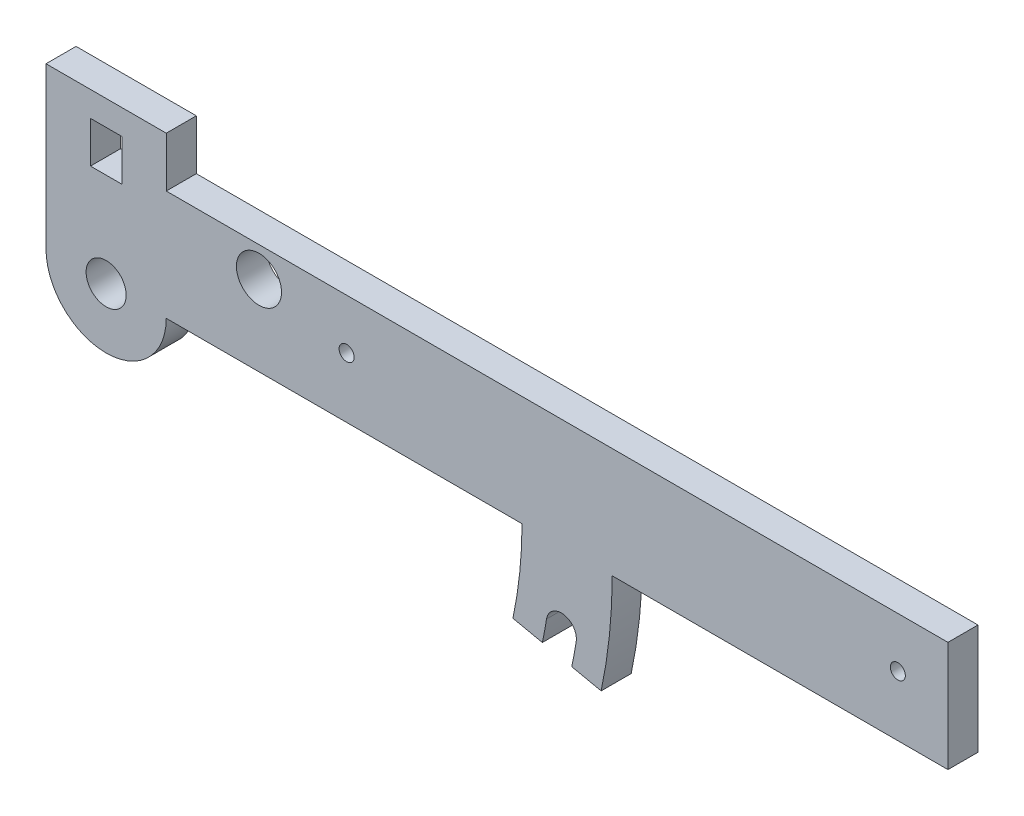
from build123d import *

# Parameters (mm, degrees)
ESBO_O1_R                = 4
ESBO_O1_R_2              = 1.5
ESBO_O1_R_3              = 4.5
ESBO_O1_W                = 6.25
ESBO_O1_H                = 8.25
RESSALTO_EXTRUS_O1_DEPTH = 6


with BuildPart() as part:
    # Esboço1 → Ressalto-extrusão1 (new body)
    with BuildSketch(Plane.XY):
        with BuildLine():
            Line((50, -7), (50, 15))
            Line((50, 15), (-106, 15))
            Line((-106, 15), (-106, 25))
            Line((-106, 25), (-130, 25))
            Line((-130, 25), (-130, -7))
            ThreePointArc((-130, -7), (-118, -19), (-106, -7))
            Line((-106, -7), (-35, -7))
            ThreePointArc((-35, -7), (-35.454682684, -15.675862451), (-36.813749139, -24.256670338))
            Line((-36.813749139, -24.256670338), (-30.944863535, -25.504140483))
            ThreePointArc((-30.944863535, -25.504140483), (-30.499970699, -23.270982524), (-30.112353587, -21.027173913))
            ThreePointArc((-30.112353587, -21.027173913), (-26.677022565, -18.537495065), (-24.187343716, -21.972826087))
            ThreePointArc((-24.187343716, -21.972826087), (-24.601092319, -24.367902694), (-25.07597793, -26.751610628))
            Line((-25.07597793, -26.751610628), (-19.207092326, -27.999080773))
            ThreePointArc((-19.207092326, -27.999080773), (-17.553288568, -17.55737479), (-17, -7))
            Line((-17, -7), (50, -7))
        make_face()
        with Locations((-118, -7)):
            Circle(ESBO_O1_R, mode=Mode.SUBTRACT)
        with Locations((-70, 5)):
            Circle(ESBO_O1_R_2, mode=Mode.SUBTRACT)
        with Locations((40, 5)):
            Circle(ESBO_O1_R_2, mode=Mode.SUBTRACT)
        with Locations((-87.5, 9)):
            Circle(ESBO_O1_R_3, mode=Mode.SUBTRACT)
        with Locations((-118, 15.875)):
            Rectangle(ESBO_O1_W, ESBO_O1_H, mode=Mode.SUBTRACT)
    extrude(amount=RESSALTO_EXTRUS_O1_DEPTH)


solid = part.part
